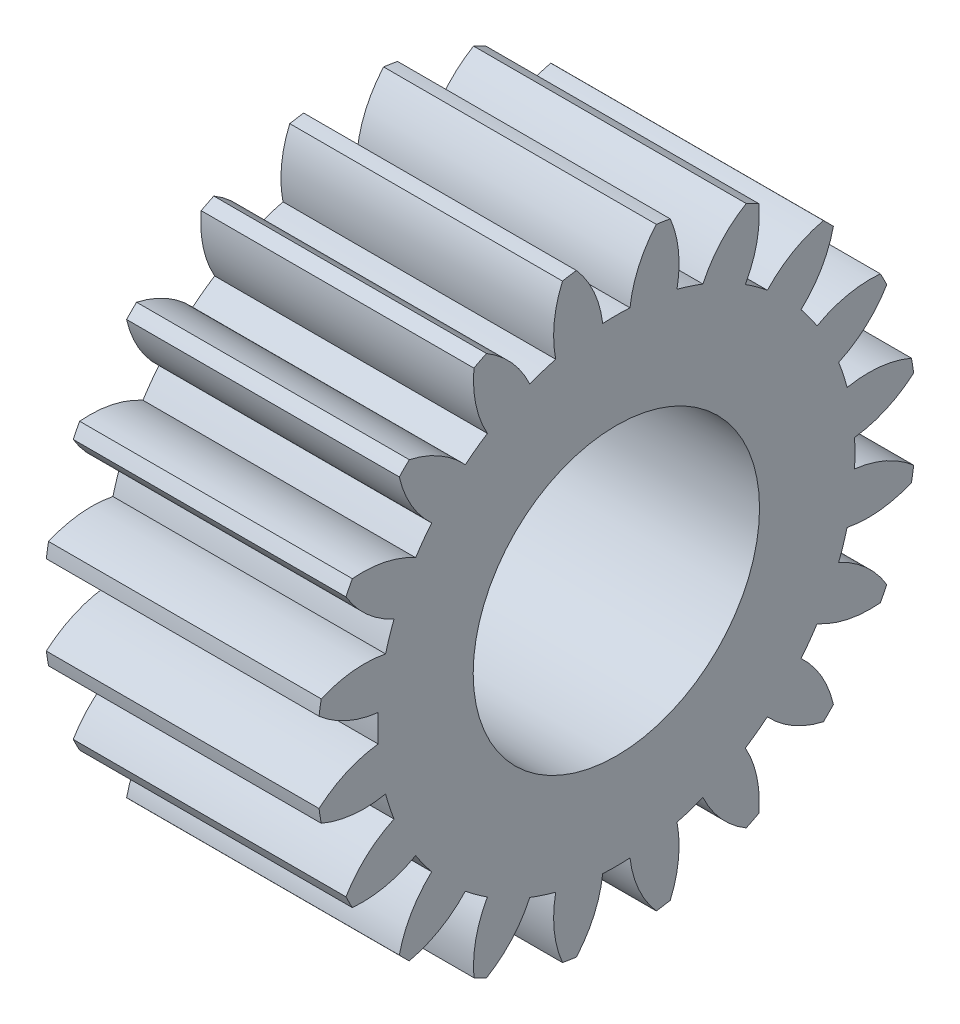
from build123d import *

# Parameters (mm, degrees)
BASPROSKE_W                   = 10
BASPROSKE_H                   = 11
TOOTHCUT_DEPTH                = 19.493242009
TEETHCUTS_COUNT               = 20
TEETHCUTS_ANGLE               = 342
BORSKE_R                      = 0.4
BORE_DEPTH                    = 50.0000508
TALADRO_DE_MARGEN_PARA_M101_D = 10.5


with BuildPart() as part:
    # BasProSke → Base-Revolve (revolve)
    with BuildSketch(Plane(origin=(0, 0, 0), x_dir=(1, 0, 0), z_dir=(0, 1, 0)), mode=Mode.PRIVATE) as base_revolve_sk:
        with Locations((5, 5.5)):
            Rectangle(BASPROSKE_W, BASPROSKE_H)
    revolve(base_revolve_sk.sketch.rotate(Axis((-10, 0, 0), (1, 0, 0)), 180), axis=Axis((-10, 0, 0), (1, 0, 0)))

    # TooCutSke → ToothCut (cut, through all)
    with BuildSketch(Plane(origin=(0, 0, 0), x_dir=(0, 0, -1), z_dir=(1, 0, 0))):
        with BuildLine():
            ThreePointArc((0.499924007, 8.734705318), (0, 8.749), (-0.499924007, 8.734705318))
            ThreePointArc((-0.499924007, 8.734705318), (-0.824302243, 9.905497836), (-1.485192705, 10.924909509))
            ThreePointArc((-1.485192705, 10.924909509), (0, 11.0254), (1.485192705, 10.924909509))
            ThreePointArc((1.485192705, 10.924909509), (0.824302243, 9.905497836), (0.499924007, 8.734705318))
        make_face()
    toothcut = extrude(amount=TOOTHCUT_DEPTH, mode=Mode.SUBTRACT)

    # TeethCuts: ToothCut ×20 about axis
    teethcuts_axis = Axis((-10, 0, 0), (1, 0, 0))
    for i in range(1, TEETHCUTS_COUNT):
        add(toothcut.rotate(teethcuts_axis, i * TEETHCUTS_ANGLE / (TEETHCUTS_COUNT - 1)), mode=Mode.SUBTRACT)

    # BorSke → Bore (cut, symmetric)
    with BuildSketch(Plane(origin=(0, 0, 0), x_dir=(0, 0, -1), z_dir=(1, 0, 0))):
        with Locations(Location((0, 0, 0), (0, 0, 180))):
            Circle(BORSKE_R)
    extrude(amount=BORE_DEPTH, both=True, mode=Mode.SUBTRACT)

    # Taladro de margen para M101 (through all)
    with Locations(Plane(origin=(10, 0, 0), x_dir=(0, 0, -1), z_dir=(1, 0, 0))):
        with Locations((0, 0)):
            Hole(TALADRO_DE_MARGEN_PARA_M101_D / 2)


solid = part.part
